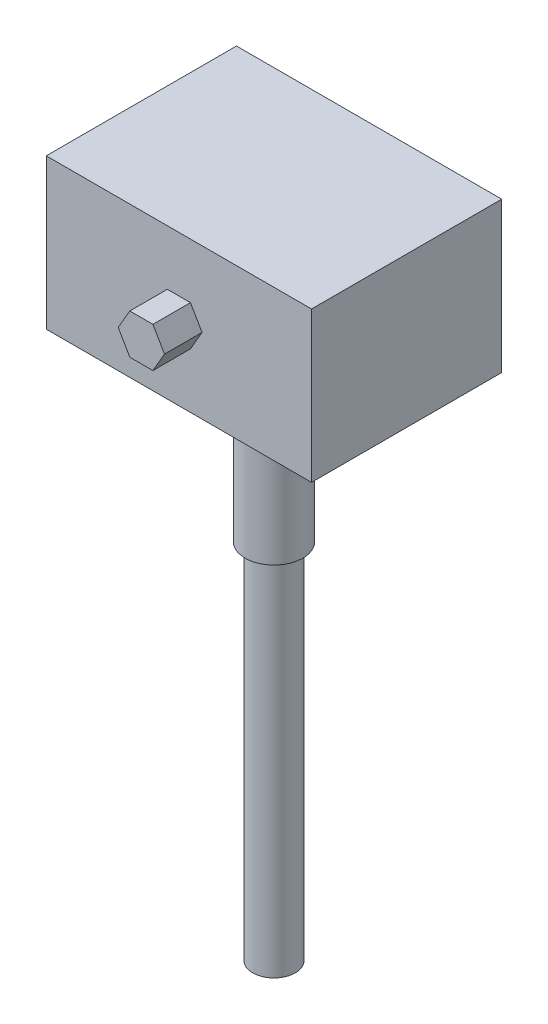
from build123d import *

# Parameters (mm, degrees)
SKETCH1_W           = 106
SKETCH1_H           = 76
BOSS_EXTRUDE1_DEPTH = 60
BOSS_EXTRUDE2_DEPTH = 15
SKETCH3_R           = 14
BOSS_EXTRUDE3_DEPTH = 15
SKETCH4_R           = 5
BOSS_EXTRUDE4_DEPTH = 11
SKETCH5_R           = 11.5
BOSS_EXTRUDE5_DEPTH = 40
SKETCH6_R           = 8.5
BOSS_EXTRUDE6_DEPTH = 145


with BuildPart() as part:
    # Sketch1 → Boss-Extrude1 (new body)
    with BuildSketch(Plane(origin=(0, 0, 0), x_dir=(1, 0, 0), z_dir=(0, 1, 0))):
        Rectangle(SKETCH1_W, SKETCH1_H)
    extrude(amount=BOSS_EXTRUDE1_DEPTH)

    # Sketch2 → Boss-Extrude2 (add)
    with BuildSketch(Plane.XY.offset(38)):
        Polygon((9.237604307, 30), (4.618802154, 38), (-4.618802154, 38), (-9.237604307, 30), (-4.618802154, 22), (4.618802154, 22), align=None)
    extrude(amount=BOSS_EXTRUDE2_DEPTH)

    # Sketch3 → Boss-Extrude3 (add)
    with BuildSketch(Plane.XZ):
        Circle(SKETCH3_R)
    extrude(amount=BOSS_EXTRUDE3_DEPTH)

    # Sketch4 → Boss-Extrude4 (add)
    with BuildSketch(Plane.XZ.offset(15)):
        Circle(SKETCH4_R)
    extrude(amount=BOSS_EXTRUDE4_DEPTH)

    # Sketch5 → Boss-Extrude5 (add)
    with BuildSketch(Plane.XZ.offset(26)):
        Circle(SKETCH5_R)
    extrude(amount=BOSS_EXTRUDE5_DEPTH)

    # Sketch6 → Boss-Extrude6 (add)
    with BuildSketch(Plane.XZ.offset(66)):
        Circle(SKETCH6_R)
    extrude(amount=BOSS_EXTRUDE6_DEPTH)


solid = part.part
